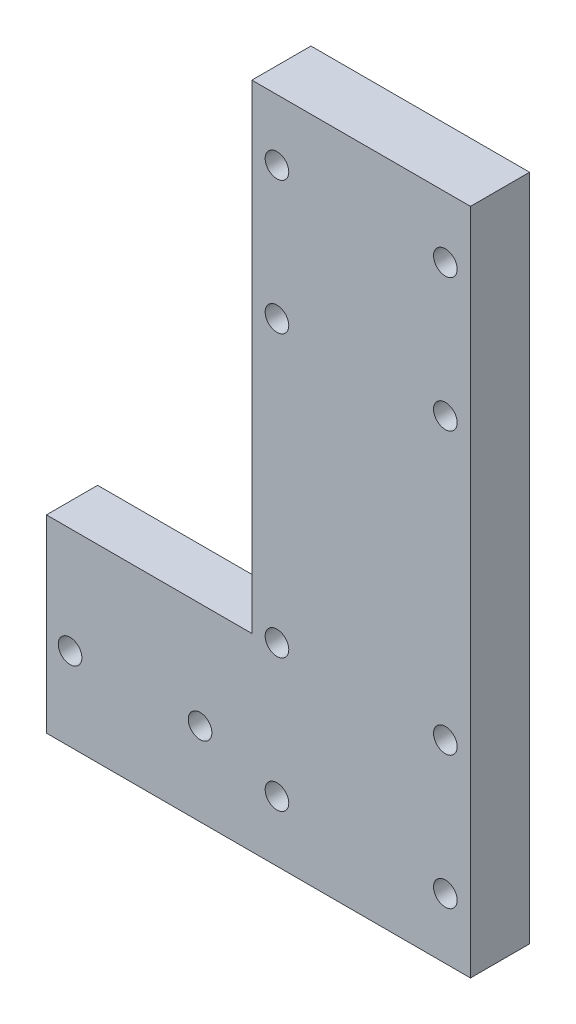
from build123d import *

# Parameters (mm, degrees)
SZKIC2_W                    = 74
SZKIC2_H                    = 226.2
DODANIE_WYCI_GNI_CIE1_DEPTH = 20
SZKIC3_W                    = 17.32
SZKIC3_H                    = 64
DODANIE_WYCI_GNI_CIE2_DEPTH = 69.53
SZKIC4_R                    = 3.999999999
WYTNIJ_WYCI_GNI_CIE1_DEPTH  = 20
SZKIC6_R                    = 4
WYTNIJ_WYCI_GNI_CIE3_DEPTH  = 21
SZKIC7_R                    = 4
WYTNIJ_WYCI_GNI_CIE4_DEPTH  = 20


with BuildPart() as part:
    # Szkic2 → Dodanie-wyciągnięcie1 (new body)
    with BuildSketch(Plane.XY.offset(-3.815865502)):
        with Locations((-0.134142184, -106.911615453)):
            Rectangle(SZKIC2_W, SZKIC2_H)
    extrude(amount=DODANIE_WYCI_GNI_CIE1_DEPTH)

    # Szkic3 → Dodanie-wyciągnięcie2 (add)
    with BuildSketch(Plane.ZY.offset(37.134142184)):
        with Locations((7.524134498, -188.011615453)):
            Rectangle(SZKIC3_W, SZKIC3_H)
    extrude(amount=DODANIE_WYCI_GNI_CIE2_DEPTH)

    # Szkic4 → Wytnij-wyciągnięcie1 (cut)
    with BuildSketch(Plane.XY.offset(16.184134498)):
        with Locations((-54.667677729, -191.906887131)):
            Circle(SZKIC4_R)
        with Locations((-98.667677729, -191.906887131)):
            Circle(SZKIC4_R)
    extrude(amount=-WYTNIJ_WYCI_GNI_CIE1_DEPTH, mode=Mode.SUBTRACT)

    # Szkic6 → Wytnij-wyciągnięcie3 (cut)
    with BuildSketch(Plane.XY.offset(-4.115865502)):
        with Locations((28.365857818, -199.506887131)):
            Circle(SZKIC6_R)
        with Locations((-28.634142182, -199.506887131)):
            Circle(SZKIC6_R)
        with Locations((-28.634142182, -154.506887131)):
            Circle(SZKIC6_R)
        with Locations((28.365857818, -154.506887131)):
            Circle(SZKIC6_R)
    extrude(amount=WYTNIJ_WYCI_GNI_CIE3_DEPTH, mode=Mode.SUBTRACT)

    # Szkic7 → Wytnij-wyciągnięcie4 (cut)
    with BuildSketch(Plane.XY.offset(-3.815865502)):
        with Locations((28.365857816, -14.506887131)):
            Circle(SZKIC7_R)
        with Locations((-28.634142184, -14.506887131)):
            Circle(SZKIC7_R)
        with Locations((-28.634142184, -59.506887131)):
            Circle(SZKIC7_R)
        with Locations((28.365857816, -59.506887131)):
            Circle(SZKIC7_R)
    extrude(amount=WYTNIJ_WYCI_GNI_CIE4_DEPTH, mode=Mode.SUBTRACT)


solid = part.part
